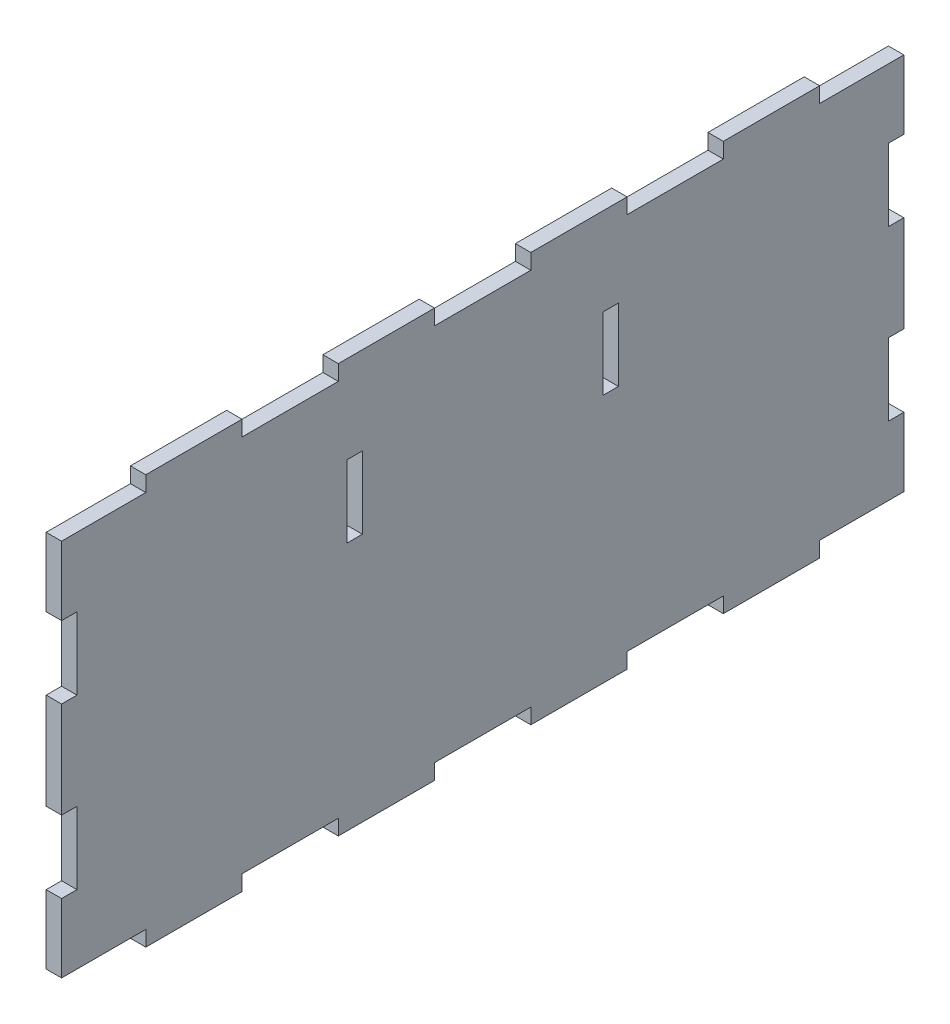
from build123d import *

# Parameters (mm, degrees)
SKETCH1_W           = 3.2
SKETCH1_H           = 15
BOSS_EXTRUDE1_DEPTH = 3.2


with BuildPart() as part:
    # Sketch1 → Boss-Extrude1 (new body)
    with BuildSketch(Plane(origin=(0, 0, 0), x_dir=(0, 0, -1), z_dir=(1, 0, 0))):
        Polygon((-10, 42.5), (-30, 42.5), (-30, 39.3), (-50, 39.3), (-50, 42.5), (-70, 42.5), (-70, 39.3), (-87.5, 39.3), (-87.5, 25), (-84.3, 25), (-84.3, 10), (-87.5, 10), (-87.5, -10), (-84.3, -10), (-84.3, -25), (-87.5, -25), (-87.5, -39.3), (-70, -39.3), (-70, -42.5), (-50, -42.5), (-50, -39.3), (-30, -39.3), (-30, -42.5), (-10, -42.5), (-10, -39.3), (10, -39.3), (10, -42.5), (30, -42.5), (30, -39.3), (50, -39.3), (50, -42.5), (70, -42.5), (70, -39.3), (87.5, -39.3), (87.5, -25), (84.3, -25), (84.3, -10), (87.5, -10), (87.5, 10), (84.3, 10), (84.3, 25), (87.5, 25), (87.5, 39.3), (70, 39.3), (70, 42.5), (50, 42.5), (50, 39.3), (30, 39.3), (30, 42.5), (10, 42.5), (10, 39.3), (-10, 39.3), align=None)
        with Locations((-26.6, 16.8)):
            Rectangle(SKETCH1_W, SKETCH1_H, mode=Mode.SUBTRACT)
        with Locations((26.6, 16.8)):
            Rectangle(SKETCH1_W, SKETCH1_H, mode=Mode.SUBTRACT)
    extrude(amount=BOSS_EXTRUDE1_DEPTH)


solid = part.part
